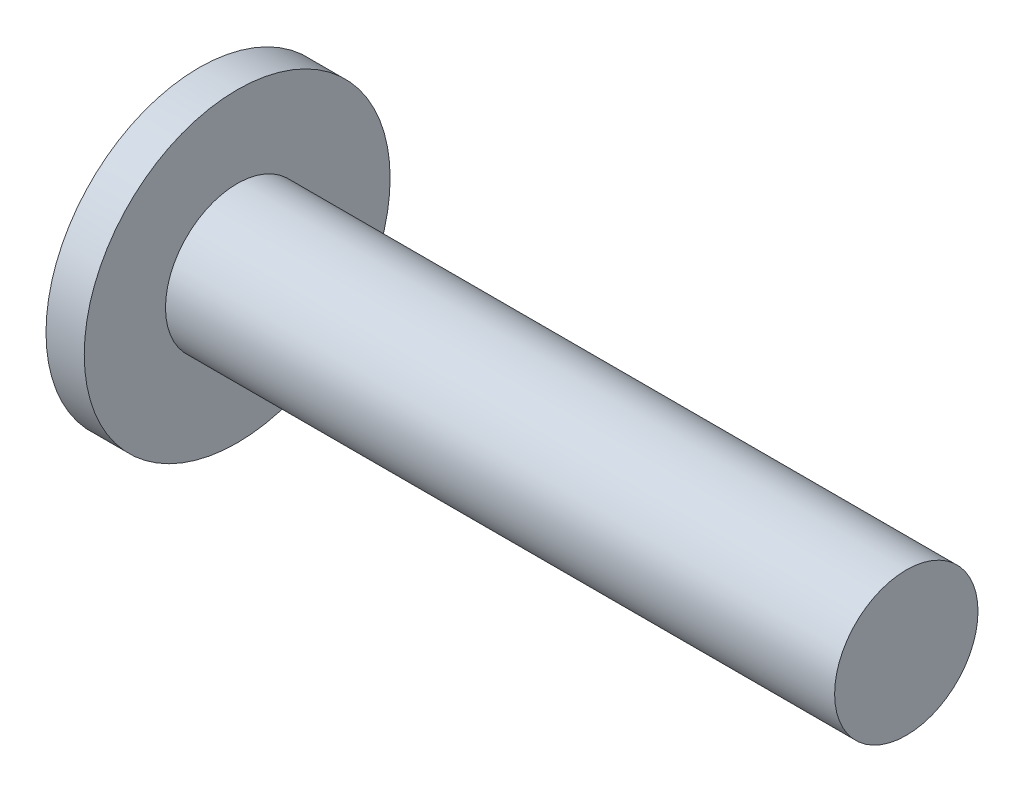
from build123d import *

# Parameters (mm, degrees)
CROQUIS1_R              = 3.75
SALIENTE_EXTRUIR1_DEPTH = 18.5
CROQUIS2_R              = 8
SALIENTE_EXTRUIR2_DEPTH = 2


with BuildPart() as part:
    # Croquis1 → Saliente-Extruir1 (new body, symmetric)
    with BuildSketch(Plane(origin=(0, 0, 0), x_dir=(0, 0, -1), z_dir=(1, 0, 0))):
        Circle(CROQUIS1_R)
    extrude(amount=SALIENTE_EXTRUIR1_DEPTH, both=True)

    # Croquis2 → Saliente-Extruir2 (add)
    with BuildSketch(Plane.ZY.offset(18.5)):
        Circle(CROQUIS2_R)
    extrude(amount=-SALIENTE_EXTRUIR2_DEPTH)


solid = part.part
